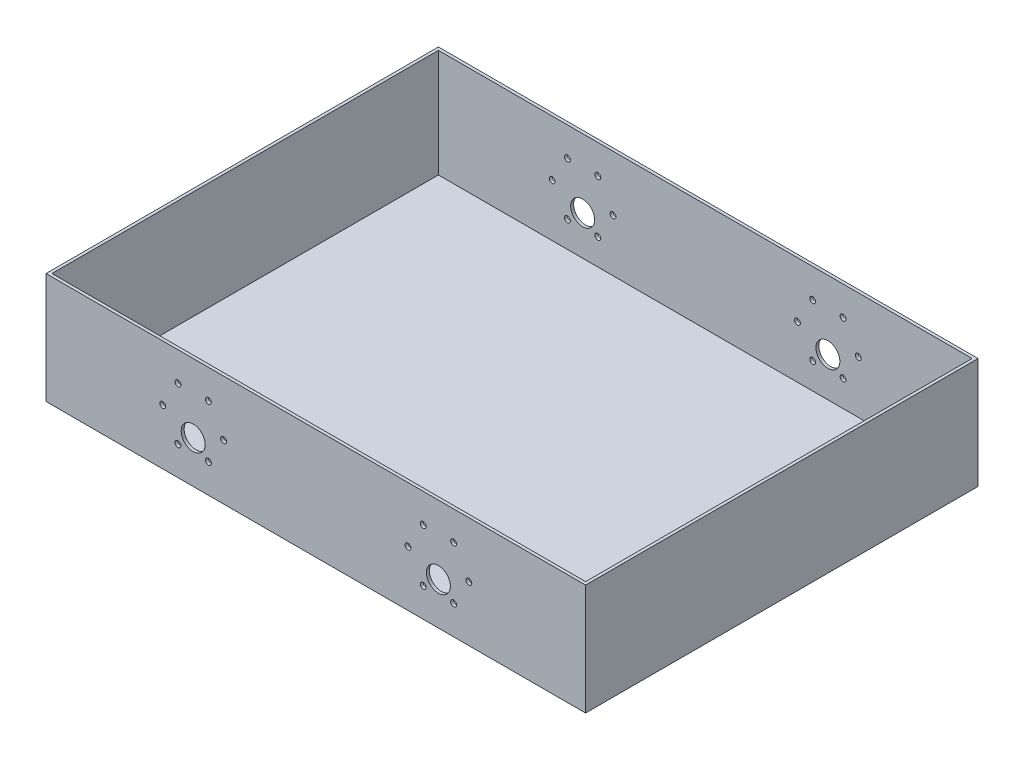
from build123d import *

# Parameters (mm, degrees)
SKETCH1_W           = 275
SKETCH1_H           = 200
BOSS_EXTRUDE1_DEPTH = 1.5
SKETCH3_W           = 275
SKETCH3_H           = 200
SKETCH3_W_2         = 272
SKETCH3_H_2         = 197
BOSS_EXTRUDE2_DEPTH = 55
SKETCH4_R           = 1.5
SKETCH4_R_2         = 6.1
MOUNT_HOLE_DEPTH    = 250


with BuildPart() as part:
    # Sketch1 → Boss-Extrude1 (new body)
    with BuildSketch(Plane(origin=(0, 0, 0), x_dir=(1, 0, 0), z_dir=(0, 1, 0))):
        Rectangle(SKETCH1_W, SKETCH1_H)
    extrude(amount=BOSS_EXTRUDE1_DEPTH)

    # Sketch3 → Boss-Extrude2 (add)
    with BuildSketch(Plane(origin=(0, 1.5, 0), x_dir=(1, 0, 0), z_dir=(0, 1, 0))):
        Rectangle(SKETCH3_W, SKETCH3_H)
        Rectangle(SKETCH3_W_2, SKETCH3_H_2, mode=Mode.SUBTRACT)
    extrude(amount=BOSS_EXTRUDE2_DEPTH)

    # Sketch4 → MOUNT HOLE (cut)
    with BuildSketch(Plane(origin=(0, 0, -100), x_dir=(-1, 0, 0), z_dir=(0, 0, -1))):
        with Locations((-47, 28.25)):
            Circle(SKETCH4_R)
        with Locations((-54.75, 14.826606241)):
            Circle(SKETCH4_R)
        with Locations((-70.25, 14.826606241)):
            Circle(SKETCH4_R)
        with Locations((-78, 28.25)):
            Circle(SKETCH4_R)
        with Locations((-70.25, 41.673393759)):
            Circle(SKETCH4_R)
        with Locations((-54.75, 41.673393759)):
            Circle(SKETCH4_R)
        with Locations((78, 28.25)):
            Circle(SKETCH4_R)
        with Locations((70.25, 14.826606241)):
            Circle(SKETCH4_R)
        with Locations((54.75, 14.826606241)):
            Circle(SKETCH4_R)
        with Locations((47, 28.25)):
            Circle(SKETCH4_R)
        with Locations((54.75, 41.673393759)):
            Circle(SKETCH4_R)
        with Locations((70.25, 41.673393759)):
            Circle(SKETCH4_R)
        with Locations((-62.5, 21.5)):
            Circle(SKETCH4_R_2)
        with Locations((62.5, 21.5)):
            Circle(SKETCH4_R_2)
    extrude(amount=-MOUNT_HOLE_DEPTH, mode=Mode.SUBTRACT)


solid = part.part
